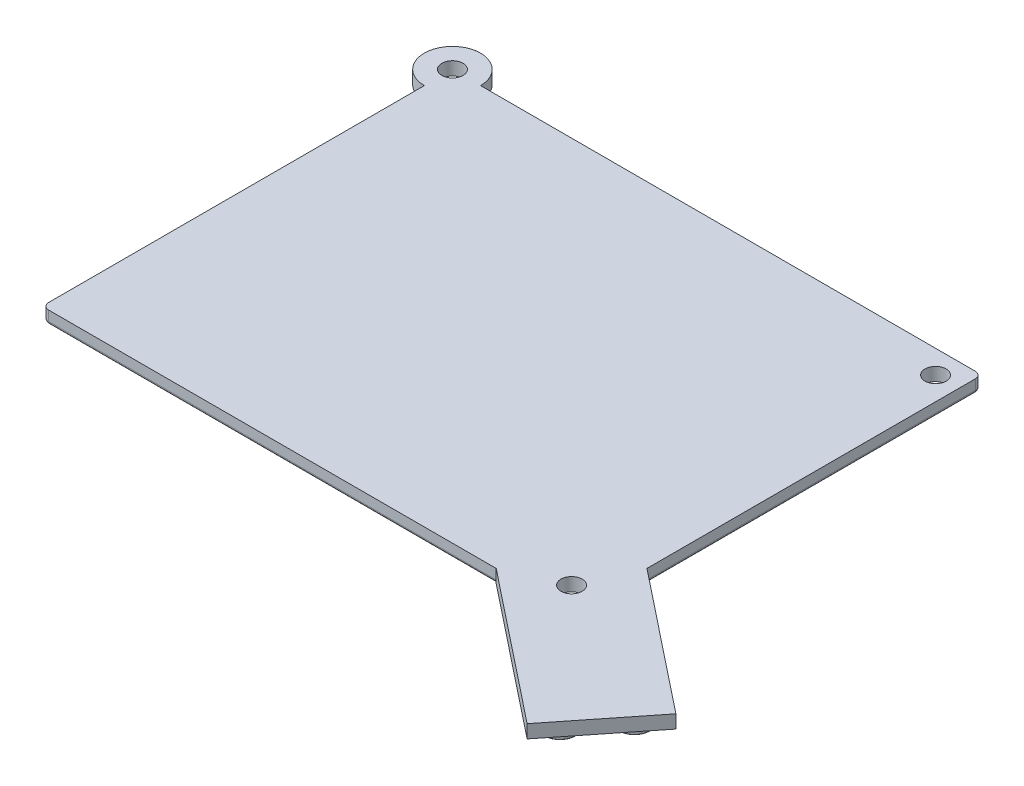
from build123d import *

# Parameters (mm, degrees)
MAIN_BODY_DEPTH        = 2
CORNERS_R              = 1
EDGE_2_R               = 0.5
DIVINGBOARD_DEPTH      = 2
SKETCH7_R              = 1.6
LID_HOLES_DEPTH        = 1.0000001
LID_HOLES_DEPTH_BACK   = 3.0000001
SKETCH4_R              = 2.325
BOSS_EXTRUDE3_DEPTH    = 1.6
FILLET3_R              = 0.05
LPATTERN5_COUNT        = 4
LPATTERN5_PITCH        = 8
FILLET3_OF_LPATTERN5_R = 0.05
SKETCH10_R             = 2.325
PEGS_DIAGONAL_DEPTH    = 1.6
FILLET4_R              = 0.05
LPATTERN6_COUNT        = 4
LPATTERN6_PITCH        = 8
FILLET4_OF_LPATTERN6_R = 0.05


with BuildPart() as part:
    # Sketch1 → Main Body (new body)
    with BuildSketch(Plane(origin=(0, 0, 0), x_dir=(1, 0, 0), z_dir=(0, 1, 0))):
        with BuildLine():
            Line((-40, -31), (40, -31))
            Line((40, -31), (40, 31))
            Line((40, 31), (-35.75, 31))
            ThreePointArc((-35.75, 31), (-43.00520382, 34.00520382), (-40, 26.75))
            Line((-40, 26.75), (-40, -31))
        make_face()
    extrude(amount=MAIN_BODY_DEPTH)

    # Corners
    corners_edges = [part.edges().sort_by_distance(p)[0] for p in [
        (40, 1, 31),
        (-40, 1, 31),
        (40, 1, -31),
    ]]
    fillet(corners_edges, radius=CORNERS_R)

    # Edge 2
    edge_2_edges = [part.edges().sort_by_distance(p)[0] for p in [
        (0, 0, 31),
        (40, 0, 0),
        (1.625, 0, -31),
        (39.707106781, 0, 30.707106781),
        (39.707106781, 0, -30.707106781),
        (-39.707106781, 0, 30.707106781),
        (-40, 0, 1.625),
    ]]
    fillet(edge_2_edges, radius=EDGE_2_R)

    # Sketch8 → DivingBoard (add)
    with BuildSketch(Plane(origin=(0, 2, 0), x_dir=(1, 0, 0), z_dir=(0, 1, 0))):
        Polygon((40, -19.611731269), (61.210680742, -36.447271473), (51.263550849, -48.979414422), (28.611731269, -31), align=None)
    extrude(amount=-DIVINGBOARD_DEPTH)

    # Sketch7 → Lid Holes (cut, two sides)
    with BuildSketch(Plane(origin=(0, 0, 0), x_dir=(-1, 0, 0), z_dir=(0, -1, 0))) as lid_holes_sk:
        with Locations((40, 31)):
            Circle(SKETCH7_R)
        with Locations((-36.5, -27.5)):
            Circle(SKETCH7_R)
        with Locations((-36.5, 27.5)):
            Circle(SKETCH7_R)
    extrude(amount=LID_HOLES_DEPTH, mode=Mode.SUBTRACT)
    extrude(lid_holes_sk.sketch, amount=-LID_HOLES_DEPTH_BACK, mode=Mode.SUBTRACT)

    # Sketch4 → Boss-Extrude3 (add)
    with BuildSketch(Plane(origin=(0, 0, 0), x_dir=(-1, 0, 0), z_dir=(0, -1, 0))):
        with Locations((-30, 24)):
            Circle(SKETCH4_R)
        with Locations((-30, 16)):
            Circle(SKETCH4_R)
    boss_extrude3 = extrude(amount=BOSS_EXTRUDE3_DEPTH)

    # Fillet3
    fillet3_edges = [part.edges().sort_by_distance(p)[0] for p in [
        (32.325, -1.6, -24),
    ]]
    fillet(fillet3_edges, radius=FILLET3_R)

    # LPattern5: Boss-Extrude3 ×4
    with Locations(*[(-i * LPATTERN5_PITCH, 0, 0) for i in range(1, LPATTERN5_COUNT)]):
        add(boss_extrude3)

    # Fillet3 of LPattern5
    fillet3_of_lpattern5_edges = [part.edges().sort_by_distance(p)[0] for p in [
        (24.325, -1.6, -24),
        (16.325, -1.6, -24),
        (8.325, -1.6, -24),
    ]]
    fillet(fillet3_of_lpattern5_edges, radius=FILLET3_OF_LPATTERN5_R)

    # Sketch10 → Pegs (Diagonal) (add)
    with BuildSketch(Plane(origin=(0, 0, 0), x_dir=(-1, 0, 0), z_dir=(0, -1, 0))):
        with Locations((-55.590862531, -37.093524737)):
            Circle(SKETCH10_R)
        with Locations((-50.617297585, -43.359596211)):
            Circle(SKETCH10_R)
    pegs_diagonal = extrude(amount=PEGS_DIAGONAL_DEPTH)

    # Fillet4
    fillet4_edges = [part.edges().sort_by_distance(p)[0] for p in [
        (52.942297585, -1.6, 43.359596211),
        (57.915862531, -1.6, 37.093524737),
    ]]
    fillet(fillet4_edges, radius=FILLET4_R)

    # LPattern6: Pegs (Diagonal) ×4
    with Locations(*[Vector(-0.783258934, 0, -0.621695618) * (i * LPATTERN6_PITCH) for i in range(1, LPATTERN6_COUNT)]):
        add(pegs_diagonal)

    # Fillet4 of LPattern6
    fillet4_of_lpattern6_edges = [part.edges().sort_by_distance(p)[0] for p in [
        (46.67622611, -1.6, 38.386031265),
        (51.649791057, -1.6, 32.11995979),
        (40.410154636, -1.6, 33.412466318),
        (45.383719582, -1.6, 27.146394844),
        (34.144083161, -1.6, 28.438901372),
        (39.117648108, -1.6, 22.172829897),
    ]]
    fillet(fillet4_of_lpattern6_edges, radius=FILLET4_OF_LPATTERN6_R)


solid = part.part
